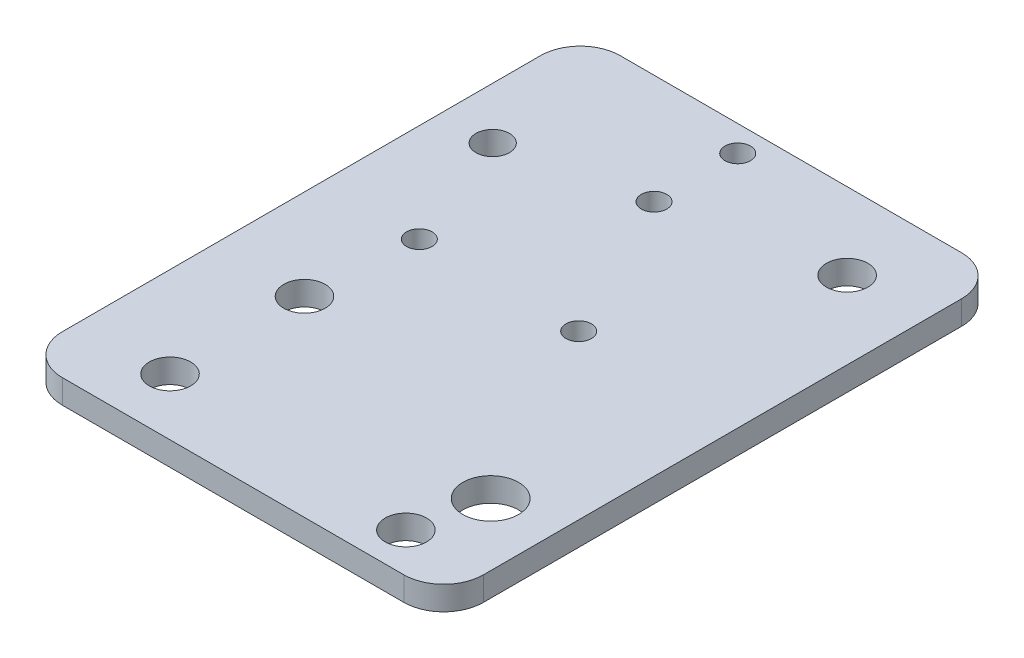
from build123d import *

# Parameters (mm, degrees)
SKETCH_1_W             = 35
SKETCH_1_H             = 70
SKETCH_1_R             = 2.6
EXTRUDE_505_DEPTH      = 3
SKETCH_2_R             = 2.1
CUT_EXTRUDE_M4_DEPTH   = 3
SKETCH_3_R             = 2.6
EXTRUDE_967_DEPTH      = 3
SKETCH_4_R             = 2.1
CUT_EXTRUDE_1312_DEPTH = 4
SKETCH_5_W             = 49
SKETCH_5_H             = 70
EXTRA_DEPTH            = 3
SKETCH_6_R             = 2.1
CUT_EXTRUDE_2055_DEPTH = 10
SKETCH_7_R             = 2.1
ETRA_DEPTH             = 10
SKETCH_10_R            = 1.6
SKETCH_10_R_2          = 3.5
CUT_EXTRUDE_3548_DEPTH = 4
FILLET_5_0_R           = 5
SKETCH_12_R            = 2.1
EXTRUDE_1_DEPTH        = 3
SKETCH_13_R            = 1.5
CUT_EXTRUDE_1_DEPTH    = 4
SKETCH_15_W            = 32.658399477
SKETCH_15_H            = 70
CUT_EXTRUDE_4_DEPTH    = 4
FILLET_6_R             = 5
SKETCH_16_R            = 1.6
SKETCH_16_R_2          = 1.603432059
EXTRUDE_2_DEPTH        = 3
SKETCH_17_R            = 2.5
CUT_EXTRUDE_5_DEPTH    = 4
SKETCH_18_R            = 1.5
EXTRUDE_3_DEPTH        = 3
SKETCH_19_R            = 1.2
CUT_EXTRUDE_6_DEPTH    = 4
SKETCH_20_R            = 2.1
SKETCH_20_R_2          = 1.6
SKETCH_20_R_3          = 2.55820294
EXTRUDE_4_DEPTH        = 3
SKETCH_22_R            = 3.5
SKETCH_22_R_2          = 2.5
EXTRUDE_5_DEPTH        = 3
SKETCH_25_R            = 2.5
CUT_EXTRUDE_9_DEPTH    = 4
SKETCH_26_R            = 2.6
SKETCH_26_R_2          = 1.6
CUT_EXTRUDE_10_DEPTH   = 4


with BuildPart() as part:
    # 草图1 → Extrude 505 (new body)
    with BuildSketch(Plane(origin=(0, 0, 0), x_dir=(1, 0, 0), z_dir=(0, 1, 0))):
        Rectangle(SKETCH_1_W, SKETCH_1_H)
        with Locations((-7.5, 22.5)):
            Circle(SKETCH_1_R, mode=Mode.SUBTRACT)
        with Locations((-7.5, 0)):
            Circle(SKETCH_1_R, mode=Mode.SUBTRACT)
        with Locations((-7.5, -22.5)):
            Circle(SKETCH_1_R, mode=Mode.SUBTRACT)
        with Locations((-7.5, 10)):
            Circle(SKETCH_1_R, mode=Mode.SUBTRACT)
        with Locations((-7.5, -10)):
            Circle(SKETCH_1_R, mode=Mode.SUBTRACT)
    extrude(amount=EXTRUDE_505_DEPTH)

    # 草图2 → M4铝柱 (cut)
    with BuildSketch(Plane(origin=(0, 3, 0), x_dir=(1, 0, 0), z_dir=(0, 1, 0))):
        with Locations((10, 0)):
            Circle(SKETCH_2_R)
    extrude(amount=-CUT_EXTRUDE_M4_DEPTH, mode=Mode.SUBTRACT)

    # 草图3 → Extrude 967 (add, through all)
    with BuildSketch(Plane(origin=(0, 3, 0), x_dir=(1, 0, 0), z_dir=(0, 1, 0))):
        with Locations((-7.5, -10)):
            Circle(SKETCH_3_R)
        with Locations((-7.5, 10)):
            Circle(SKETCH_3_R)
    extrude(amount=-EXTRUDE_967_DEPTH)

    # 草图4 → Cut-Extrude 1312 (cut, through all)
    with BuildSketch(Plane(origin=(0, 3, 0), x_dir=(1, 0, 0), z_dir=(0, 1, 0))):
        with Locations((10, 22.5)):
            Circle(SKETCH_4_R)
        with Locations((10, -22.5)):
            Circle(SKETCH_4_R)
    extrude(amount=-CUT_EXTRUDE_1312_DEPTH, mode=Mode.SUBTRACT)

    # 草图5 → EXTRA (add, through all)
    with BuildSketch(Plane(origin=(0, 3, 0), x_dir=(1, 0, 0), z_dir=(0, 1, 0))):
        with Locations((-42, 0)):
            Rectangle(SKETCH_5_W, SKETCH_5_H)
    extrude(amount=-EXTRA_DEPTH)

    # 草图6 → Cut-Extrude 2055 (cut)
    with BuildSketch(Plane(origin=(0, 3, 0), x_dir=(1, 0, 0), z_dir=(0, 1, 0))):
        with Locations((-44.5, 0)):
            Circle(SKETCH_6_R)
        with Locations((-36.5, 0)):
            Circle(SKETCH_6_R)
    extrude(amount=-CUT_EXTRUDE_2055_DEPTH, mode=Mode.SUBTRACT)

    # 草图7 → ETRA铝柱 (cut)
    with BuildSketch(Plane(origin=(0, 3, 0), x_dir=(1, 0, 0), z_dir=(0, 1, 0))):
        with Locations((-60, 17.5)):
            Circle(SKETCH_7_R)
        with Locations((-60, -17.5)):
            Circle(SKETCH_7_R)
    extrude(amount=-ETRA_DEPTH, mode=Mode.SUBTRACT)

    # 草图10 → Cut-Extrude 3548 (cut, through all)
    with BuildSketch(Plane.XZ):
        with Locations((-43.5, -21.25)):
            Circle(SKETCH_10_R)
        with Locations((-21.5, -31.75)):
            Circle(SKETCH_10_R)
        with Locations((-43.5, -31.75)):
            Circle(SKETCH_10_R)
        with Locations((-43.5, 21.25)):
            Circle(SKETCH_10_R)
        with Locations((-21.5, 31.75)):
            Circle(SKETCH_10_R)
        with Locations((-43.5, 31.75)):
            Circle(SKETCH_10_R)
        with Locations((-21.5, 21.25)):
            Circle(SKETCH_10_R_2)
        with Locations((-21.5, -21.25)):
            Circle(SKETCH_10_R_2)
    extrude(amount=-CUT_EXTRUDE_3548_DEPTH, mode=Mode.SUBTRACT)

    # 圆角5.0
    fillet_5_0_edges = [part.edges().sort_by_distance(p)[0] for p in [
        (-66.5, 1.5, 35),
        (-66.5, 1.5, -35),
        (17.5, 1.5, 35),
        (17.5, 1.5, -35),
    ]]
    fillet(fillet_5_0_edges, radius=FILLET_5_0_R)

    # 草图12 → 凸台-拉伸1 (add)
    with BuildSketch(Plane(origin=(0, 3, 0), x_dir=(1, 0, 0), z_dir=(0, 1, 0))):
        with Locations((-36.5, 0)):
            Circle(SKETCH_12_R)
        with Locations((-44.5, 0)):
            Circle(SKETCH_12_R)
    extrude(amount=-EXTRUDE_1_DEPTH)

    # 草图13 → 切除-拉伸1 (cut, through all)
    with BuildSketch(Plane(origin=(0, 3, 0), x_dir=(1, 0, 0), z_dir=(0, 1, 0))):
        with Locations((-52.499999555, 1.426e-06)):
            Circle(SKETCH_13_R)
        with Locations((-28.499999555, 1.44e-06)):
            Circle(SKETCH_13_R)
    extrude(amount=-CUT_EXTRUDE_1_DEPTH, mode=Mode.SUBTRACT)

    # 草图15 → 切除-拉伸4 (cut, through all)
    with BuildSketch(Plane(origin=(0, 3, 0), x_dir=(1, 0, 0), z_dir=(0, 1, 0))):
        with Locations((2.675548589, 0)):
            Rectangle(SKETCH_15_W, SKETCH_15_H)
    extrude(amount=-CUT_EXTRUDE_4_DEPTH, mode=Mode.SUBTRACT)

    # 圆角6
    fillet_6_edges = [part.edges().sort_by_distance(p)[0] for p in [
        (-13.653651149, 1.5, -35),
        (-13.653651149, 1.5, 35),
    ]]
    fillet(fillet_6_edges, radius=FILLET_6_R)

    # 草图16 → 凸台-拉伸2 (add)
    with BuildSketch(Plane.XZ):
        with Locations((-21.5, 31.75)):
            Circle(SKETCH_16_R)
        with Locations((-21.5, -31.75)):
            Circle(SKETCH_16_R_2)
    extrude(amount=-EXTRUDE_2_DEPTH)

    # 草图17 → 切除-拉伸5 (cut, through all)
    with BuildSketch(Plane(origin=(0, 3, 0), x_dir=(1, 0, 0), z_dir=(0, 1, 0))):
        with Locations((-23.393651149, -30)):
            Circle(SKETCH_17_R)
        with Locations((-24.763651149, 30)):
            Circle(SKETCH_17_R)
    extrude(amount=-CUT_EXTRUDE_5_DEPTH, mode=Mode.SUBTRACT)

    # 草图18 → 凸台-拉伸3 (add)
    with BuildSketch(Plane.XZ):
        with Locations((-52.499999555, -1.426e-06)):
            Circle(SKETCH_18_R)
        with Locations((-28.499999555, -1.44e-06)):
            Circle(SKETCH_18_R)
    extrude(amount=-EXTRUDE_3_DEPTH)

    # 草图19 → 切除-拉伸6 (cut, through all)
    with BuildSketch(Plane.XZ):
        with Locations((-54.153651149, -2.448052536)):
            Circle(SKETCH_19_R)
        with Locations((-34.153651149, -2.448052536)):
            Circle(SKETCH_19_R)
    extrude(amount=-CUT_EXTRUDE_6_DEPTH, mode=Mode.SUBTRACT)

    # 草图20 → 凸台-拉伸4 (add)
    with BuildSketch(Plane.XZ):
        with Locations((-60, 17.5)):
            Circle(SKETCH_20_R)
        with Locations((-43.5, 21.25)):
            Circle(SKETCH_20_R_2)
        with Locations((-43.653651149, 31.685692809)):
            Circle(SKETCH_20_R_3)
    extrude(amount=-EXTRUDE_4_DEPTH)

    # 草图22 → 凸台-拉伸5 (add)
    with BuildSketch(Plane(origin=(0, 0, 0), x_dir=(-1, 0, 0), z_dir=(0, -1, 0))):
        with Locations((21.5, 21.25)):
            Circle(SKETCH_22_R)
        with Locations((24.763651149, 30)):
            Circle(SKETCH_22_R_2)
    extrude(amount=-EXTRUDE_5_DEPTH)

    # 草图25 → 切除-拉伸9 (cut, through all)
    with BuildSketch(Plane(origin=(0, 3, 0), x_dir=(1, 0, 0), z_dir=(0, 1, 0))):
        with Locations((-23.393651149, 25.376236088)):
            Circle(SKETCH_25_R)
    extrude(amount=-CUT_EXTRUDE_9_DEPTH, mode=Mode.SUBTRACT)

    # 草图26 → 切除-拉伸10 (cut, through all)
    with BuildSketch(Plane.XZ):
        with Locations((-55.153651029, 27.841992404)):
            Circle(SKETCH_26_R)
        with Locations((-23.393651149, -25.376236088)):
            Circle(SKETCH_26_R)
        with Locations((-23.393651149, 30)):
            Circle(SKETCH_26_R)
        with Locations((-55.153651029, 10.96736207)):
            Circle(SKETCH_26_R)
        with Locations((-54.153651149, -2.448052536)):
            Circle(SKETCH_26_R_2)
        with Locations((-34.153651149, -2.448052536)):
            Circle(SKETCH_26_R_2)
    extrude(amount=-CUT_EXTRUDE_10_DEPTH, mode=Mode.SUBTRACT)


solid = part.part
